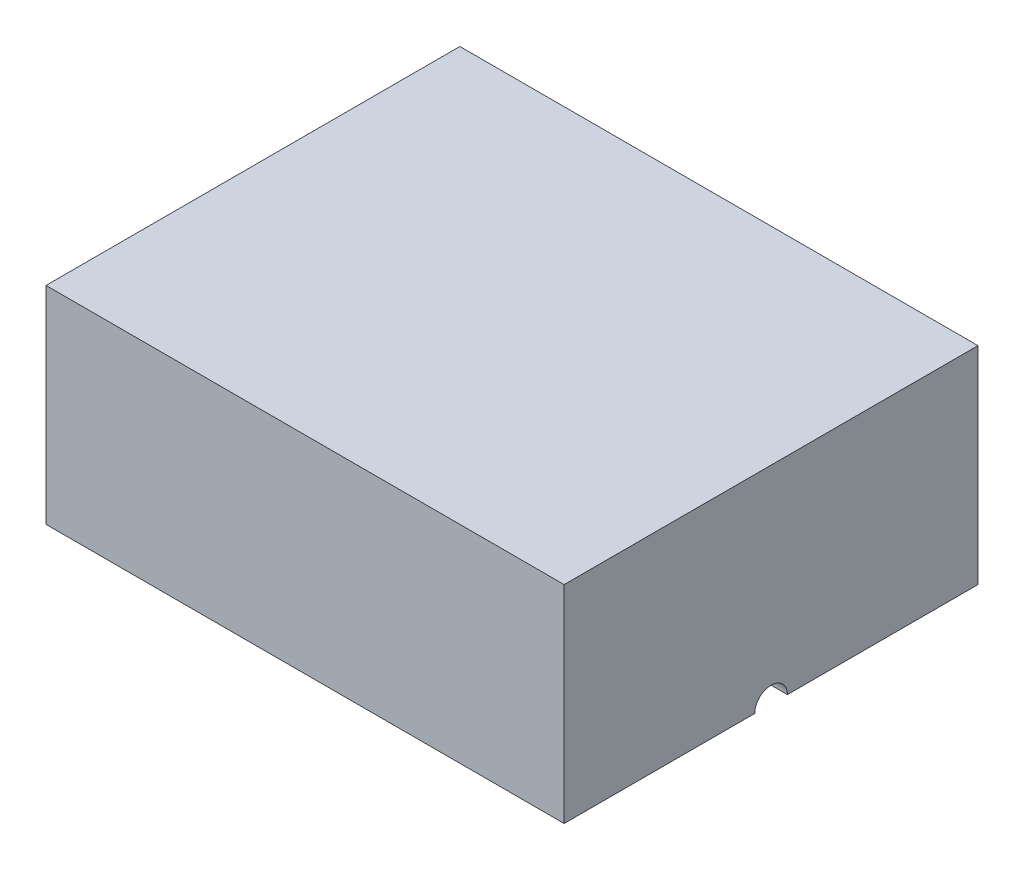
from build123d import *

# Parameters (mm, degrees)
SKETCH1_W           = 31.8
SKETCH1_H           = 25.4
BOSS_EXTRUDE1_DEPTH = 12.7
CUT_REVOLVE8_ANGLE  = 360
SKETCH7_R           = 1
CUT_EXTRUDE1_DEPTH  = 32.8000001


with BuildPart() as part:
    # Sketch1 → Boss-Extrude1 (new body)
    with BuildSketch(Plane(origin=(0, 0, 0), x_dir=(1, 0, 0), z_dir=(0, 1, 0))):
        Rectangle(SKETCH1_W, SKETCH1_H)
    extrude(amount=BOSS_EXTRUDE1_DEPTH)

    # Sketch2 → Cut-Revolve8 (revolve, symmetric, cut)
    with BuildSketch(Plane.XZ) as cut_revolve8_sk:
        with BuildLine():
            Line((-14, 0), (14, 0))
            add(Edge.make_bspline(
                [(14, 0), (14, 9.38), (0, 9.38)],
                knots=[3.141592654, 3.141592654, 3.141592654, 4.71238898, 4.71238898, 4.71238898], degree=2, weights=[1, 0.707106781, 1]))
            add(Edge.make_bspline(
                [(0, 9.38), (-14, 9.38), (-14, 0)],
                knots=[1.570796327, 1.570796327, 1.570796327, 3.141592654, 3.141592654, 3.141592654], degree=2, weights=[1, 0.707106781, 1]))
        make_face()
    revolve(axis=Axis((0, 0, 0), (1, 0, 0)), revolution_arc=CUT_REVOLVE8_ANGLE / 2, mode=Mode.SUBTRACT)
    revolve(cut_revolve8_sk.sketch, axis=Axis((0, 0, 0), (-1, 0, 0)), revolution_arc=CUT_REVOLVE8_ANGLE / 2, mode=Mode.SUBTRACT)

    # Sketch7 → Cut-Extrude1 (cut, through all)
    with BuildSketch(Plane(origin=(15.9, 0, 0), x_dir=(0, 0, -1), z_dir=(1, 0, 0))):
        Circle(SKETCH7_R)
    extrude(amount=-CUT_EXTRUDE1_DEPTH, mode=Mode.SUBTRACT)


solid = part.part
